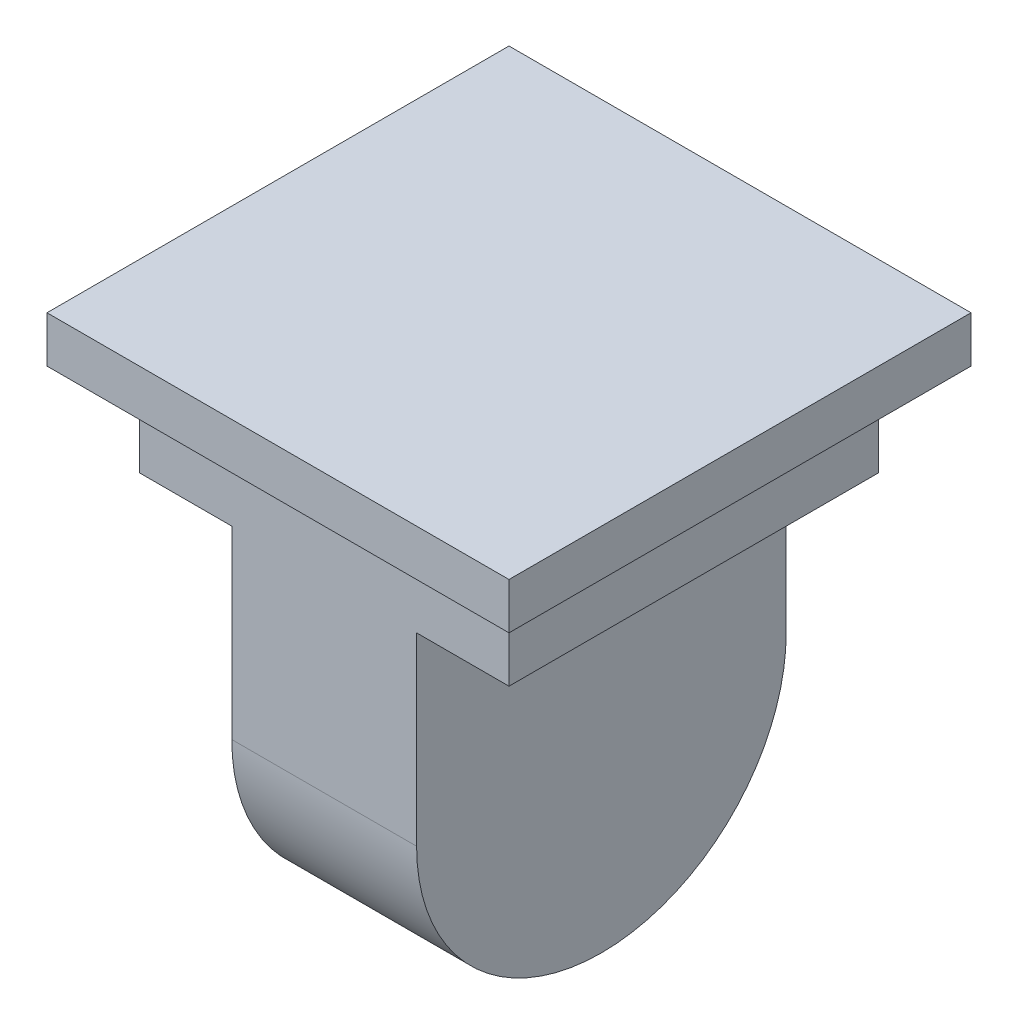
from build123d import *

# Parameters (mm, degrees)
SKETCH_1_W          = 16
SKETCH_1_H          = 16
EXTRUDE_1_DEPTH     = 20
CUT_EXTRUDE_1_DEPTH = 40
CUT_EXTRUDE_2_DEPTH = 4
CUT_EXTRUDE_3_DEPTH = 4
SKETCH_6_W          = 20
SKETCH_6_H          = 20
EXTRUDE_2_DEPTH     = 2


with BuildPart() as part:
    # 草图1 → 凸台-拉伸1 (new body)
    with BuildSketch(Plane(origin=(0, 0, 0), x_dir=(1, 0, 0), z_dir=(0, 1, 0))):
        Rectangle(SKETCH_1_W, SKETCH_1_H)
    extrude(amount=EXTRUDE_1_DEPTH)

    # 草图2 → 切除-拉伸1 (cut)
    with BuildSketch(Plane(origin=(8, 0, 0), x_dir=(0, 0, -1), z_dir=(1, 0, 0))):
        with BuildLine():
            Line((-8, 8), (-8, -6.748551072))
            Line((-8, -6.748551072), (8, -6.748551072))
            Line((8, -6.748551072), (8, 8))
            ThreePointArc((8, 8), (0, 0), (-8, 8))
        make_face()
    extrude(amount=-CUT_EXTRUDE_1_DEPTH, mode=Mode.SUBTRACT)

    # 草图4 → 切除-拉伸2 (cut)
    with BuildSketch(Plane.ZY.offset(8)):
        with BuildLine():
            Line((-8, 8), (-8, 16))
            Line((-8, 16), (8, 16))
            Line((8, 16), (8, 8))
            ThreePointArc((8, 8), (0, 0), (-8, 8))
        make_face()
    extrude(amount=-CUT_EXTRUDE_2_DEPTH, mode=Mode.SUBTRACT)

    # 草图5 → 切除-拉伸3 (cut)
    with BuildSketch(Plane(origin=(8, 0, 0), x_dir=(0, 0, -1), z_dir=(1, 0, 0))):
        with BuildLine():
            Line((-8, 8), (-8, 16))
            Line((-8, 16), (8, 16))
            Line((8, 16), (8, 8))
            ThreePointArc((8, 8), (0, 0), (-8, 8))
        make_face()
    extrude(amount=-CUT_EXTRUDE_3_DEPTH, mode=Mode.SUBTRACT)

    # 草图6 → 凸台-拉伸2 (add)
    with BuildSketch(Plane(origin=(0, 20, 0), x_dir=(1, 0, 0), z_dir=(0, 1, 0))):
        Rectangle(SKETCH_6_W, SKETCH_6_H)
    extrude(amount=EXTRUDE_2_DEPTH)


solid = part.part
